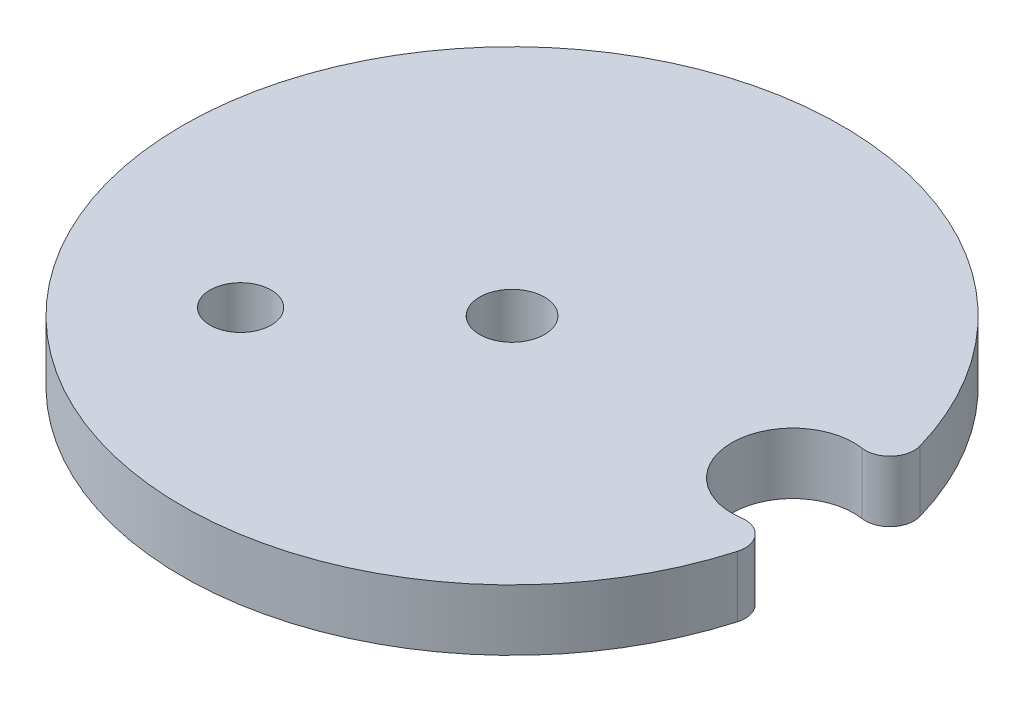
from build123d import *

# Parameters (mm, degrees)
BOSS_EXTRUDE1_DEPTH     = 6.35
F_1_4_CLEARANCE_HOLE1_D = 6.7564
FILLET1_R               = 2.54
SKETCH4_R               = 3.175
CUT_EXTRUDE1_DEPTH      = 7.3500001


with BuildPart() as part:
    # Sketch1 → Boss-Extrude1 (new body)
    with BuildSketch(Plane(origin=(0, 0, 0), x_dir=(1, 0, 0), z_dir=(0, 1, 0))):
        with BuildLine():
            ThreePointArc((34.041521739, -4.120545799), (22.86, 0), (34.041521739, 4.120545799))
            ThreePointArc((34.041521739, 4.120545799), (-34.29, 0), (34.041521739, -4.120545799))
        make_face()
    extrude(amount=BOSS_EXTRUDE1_DEPTH)

    # 1/4 Clearance Hole1 (through all)
    with Locations(Plane(origin=(0, 6.35, 0), x_dir=(1, 0, 0), z_dir=(0, 1, 0))):
        with Locations((0, 0)):
            Hole(F_1_4_CLEARANCE_HOLE1_D / 2)

    # Fillet1
    fillet1_edges = [part.edges().sort_by_distance(p)[0] for p in [
        (34.041521739, 3.175, 4.120545799),
        (34.041521739, 3.175, -4.120545799),
    ]]
    fillet(fillet1_edges, radius=FILLET1_R)

    # Sketch4 → Cut-Extrude1 (cut, through all)
    with BuildSketch(Plane(origin=(0, 6.35, 0), x_dir=(1, 0, 0), z_dir=(0, 1, 0))):
        with Locations((-14.86289651, -13.382612127)):
            Circle(SKETCH4_R)
    extrude(amount=-CUT_EXTRUDE1_DEPTH, mode=Mode.SUBTRACT)


solid = part.part
